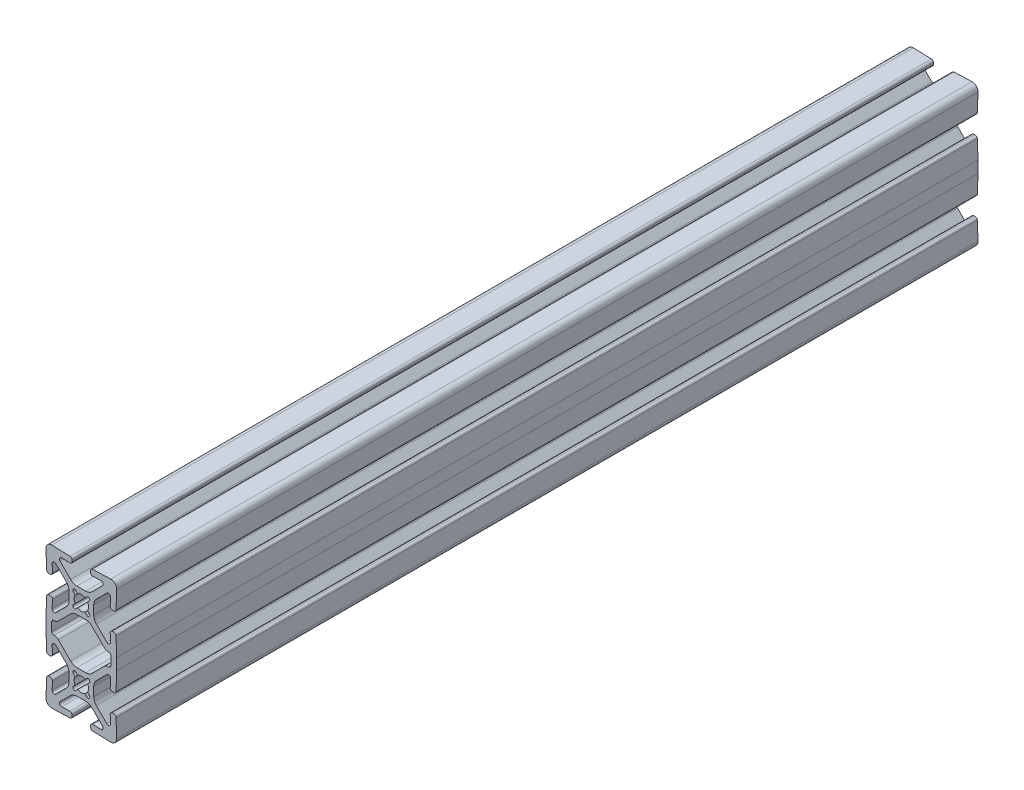
from build123d import *

# Parameters (mm, degrees)
BOSS_EXTRUDE1_DEPTH = 152.4
CIRPATTERN1_COUNT   = 2


with BuildPart() as part:
    # Sketch3 → Boss-Extrude1 (new body, symmetric)
    with BuildSketch(Plane.XY):
        with BuildLine():
            Line((-4.38, 10.941265504), (-4.38, 14.058734496))
            ThreePointArc((-4.38, 14.058734496), (-4.621682484, 15.273754393), (-5.30993597, 16.303798526))
            Line((-5.30993597, 16.303798526), (-9.020191678, 20.014054234))
            ThreePointArc((-9.020191678, 20.014054234), (-9.863839779, 20.17422583), (-10.32206431, 19.447983903))
            Line((-10.32206431, 19.447983903), (-10.221143342, 16.5579855))
            ThreePointArc((-10.221143342, 16.5579855), (-10.425626604, 16.011070171), (-10.956945643, 15.768934135))
            Line((-10.956945643, 15.768934135), (-11.485840127, 15.750464733))
            ThreePointArc((-11.485840127, 15.750464733), (-12.032755455, 15.954947995), (-12.274891491, 16.486267034))
            Line((-12.274891491, 16.486267034), (-12.498762161, 22.897084223))
            ThreePointArc((-12.498762161, 22.897084223), (-11.904840979, 24.404840979), (-10.397084223, 24.998762161))
            Line((-10.397084223, 24.998762161), (-3.986267034, 24.774891491))
            ThreePointArc((-3.986267034, 24.774891491), (-3.454947995, 24.532755455), (-3.250464733, 23.985840127))
            Line((-3.250464733, 23.985840127), (-3.268934135, 23.456945643))
            ThreePointArc((-3.268934135, 23.456945643), (-3.511070171, 22.925626604), (-4.0579855, 22.721143342))
            Line((-4.0579855, 22.721143342), (-6.947983903, 22.82206431))
            ThreePointArc((-6.947983903, 22.82206431), (-7.67422583, 22.363839779), (-7.514054234, 21.520191678))
            Line((-7.514054234, 21.520191678), (-3.803798526, 17.80993597))
            ThreePointArc((-3.803798526, 17.80993597), (-2.773754393, 17.121682484), (-1.558734496, 16.88))
            Line((-1.558734496, 16.88), (1.558734496, 16.88))
            ThreePointArc((1.558734496, 16.88), (2.773754393, 17.121682484), (3.803798526, 17.80993597))
            Line((3.803798526, 17.80993597), (7.514054234, 21.520191678))
            ThreePointArc((7.514054234, 21.520191678), (7.67422583, 22.363839779), (6.947983903, 22.82206431))
            Line((6.947983903, 22.82206431), (4.0579855, 22.721143342))
            ThreePointArc((4.0579855, 22.721143342), (3.511070171, 22.925626604), (3.268934135, 23.456945643))
            Line((3.268934135, 23.456945643), (3.250464733, 23.985840127))
            ThreePointArc((3.250464733, 23.985840127), (3.454947995, 24.532755455), (3.986267034, 24.774891491))
            Line((3.986267034, 24.774891491), (10.397084223, 24.998762161))
            ThreePointArc((10.397084223, 24.998762161), (11.904840979, 24.404840979), (12.498762161, 22.897084223))
            Line((12.498762161, 22.897084223), (12.274891491, 16.486267034))
            ThreePointArc((12.274891491, 16.486267034), (12.032755455, 15.954947995), (11.485840127, 15.750464733))
            Line((11.485840127, 15.750464733), (10.956945643, 15.768934135))
            ThreePointArc((10.956945643, 15.768934135), (10.425626604, 16.011070171), (10.221143342, 16.5579855))
            Line((10.221143342, 16.5579855), (10.32206431, 19.447983903))
            ThreePointArc((10.32206431, 19.447983903), (9.863839779, 20.17422583), (9.020191678, 20.014054234))
            Line((9.020191678, 20.014054234), (5.30993597, 16.303798526))
            ThreePointArc((5.30993597, 16.303798526), (4.621682484, 15.273754393), (4.38, 14.058734496))
            Line((4.38, 14.058734496), (4.38, 10.941265504))
            ThreePointArc((4.38, 10.941265504), (4.621682484, 9.726245607), (5.30993597, 8.696201474))
            Line((5.30993597, 8.696201474), (9.020191678, 4.985945766))
            ThreePointArc((9.020191678, 4.985945766), (9.863839779, 4.82577417), (10.32206431, 5.552016097))
            Line((10.32206431, 5.552016097), (10.221143342, 8.4420145))
            ThreePointArc((10.221143342, 8.4420145), (10.425626604, 8.988929829), (10.956945643, 9.231065865))
            Line((10.956945643, 9.231065865), (11.485840127, 9.249535267))
            ThreePointArc((11.485840127, 9.249535267), (12.032755455, 9.045052005), (12.274891491, 8.513732966))
            Line((12.274891491, 8.513732966), (12.5, 2.067468692))
            Line((12.5, 2.067468692), (12.5, 0))
            Line((12.5, 0), (10.468, 0))
            Line((10.468, 0), (10.468, 1.506))
            ThreePointArc((10.468, 1.506), (10.244815367, 2.044815367), (9.706, 2.268))
            Line((9.706, 2.268), (9.567544515, 2.268))
            ThreePointArc((9.567544515, 2.268), (8.78993178, 2.42267679), (8.130703535, 2.863159021))
            Line((8.130703535, 2.863159021), (3.803798526, 7.19006403))
            ThreePointArc((3.803798526, 7.19006403), (2.773754393, 7.878317516), (1.558734496, 8.12))
            Line((1.558734496, 8.12), (-1.558734496, 8.12))
            ThreePointArc((-1.558734496, 8.12), (-2.773754393, 7.878317516), (-3.803798526, 7.19006403))
            Line((-3.803798526, 7.19006403), (-8.130703535, 2.863159021))
            ThreePointArc((-8.130703535, 2.863159021), (-8.78993178, 2.42267679), (-9.567544515, 2.268))
            Line((-9.567544515, 2.268), (-9.706, 2.268))
            ThreePointArc((-9.706, 2.268), (-10.244815367, 2.044815367), (-10.468, 1.506))
            Line((-10.468, 1.506), (-10.468, 0))
            Line((-10.468, 0), (-12.5, 0))
            Line((-12.5, 0), (-12.5, 2.067468692))
            Line((-12.5, 2.067468692), (-12.274891491, 8.513732966))
            ThreePointArc((-12.274891491, 8.513732966), (-12.032755455, 9.045052005), (-11.485840127, 9.249535267))
            Line((-11.485840127, 9.249535267), (-10.956945643, 9.231065865))
            ThreePointArc((-10.956945643, 9.231065865), (-10.425626604, 8.988929829), (-10.221143342, 8.4420145))
            Line((-10.221143342, 8.4420145), (-10.32206431, 5.552016097))
            ThreePointArc((-10.32206431, 5.552016097), (-9.863839779, 4.82577417), (-9.020191678, 4.985945766))
            Line((-9.020191678, 4.985945766), (-5.30993597, 8.696201474))
            ThreePointArc((-5.30993597, 8.696201474), (-4.621682484, 9.726245607), (-4.38, 10.941265504))
        make_face()
        with BuildLine():
            Line((-2.828427125, 14.430401513), (-2.195333939, 13.797308327))
            ThreePointArc((-2.195333939, 13.797308327), (-2.55, 12.5), (-2.195333939, 11.202691673))
            Line((-2.195333939, 11.202691673), (-2.828427125, 10.569598487))
            ThreePointArc((-2.828427125, 10.569598487), (-2.828427125, 9.671572875), (-1.930401513, 9.671572875))
            Line((-1.930401513, 9.671572875), (-1.297308327, 10.304666061))
            ThreePointArc((-1.297308327, 10.304666061), (0, 9.95), (1.297308327, 10.304666061))
            Line((1.297308327, 10.304666061), (1.930401513, 9.671572875))
            ThreePointArc((1.930401513, 9.671572875), (2.828427125, 9.671572875), (2.828427125, 10.569598487))
            Line((2.828427125, 10.569598487), (2.195333939, 11.202691673))
            ThreePointArc((2.195333939, 11.202691673), (2.55, 12.5), (2.195333939, 13.797308327))
            Line((2.195333939, 13.797308327), (2.828427125, 14.430401513))
            ThreePointArc((2.828427125, 14.430401513), (2.828427125, 15.328427125), (1.930401513, 15.328427125))
            Line((1.930401513, 15.328427125), (1.297308327, 14.695333939))
            ThreePointArc((1.297308327, 14.695333939), (0, 15.05), (-1.297308327, 14.695333939))
            Line((-1.297308327, 14.695333939), (-1.930401513, 15.328427125))
            ThreePointArc((-1.930401513, 15.328427125), (-2.828427125, 15.328427125), (-2.828427125, 14.430401513))
        make_face(mode=Mode.SUBTRACT)
    boss_extrude1 = extrude(amount=BOSS_EXTRUDE1_DEPTH, both=True)

    # CirPattern1: Boss-Extrude1 ×2 about axis
    cirpattern1_axis = Axis((0, 0, 0), (0, 0, 1))
    for i in range(1, CIRPATTERN1_COUNT):
        add(boss_extrude1.rotate(cirpattern1_axis, i * 360 / CIRPATTERN1_COUNT))


solid = part.part
